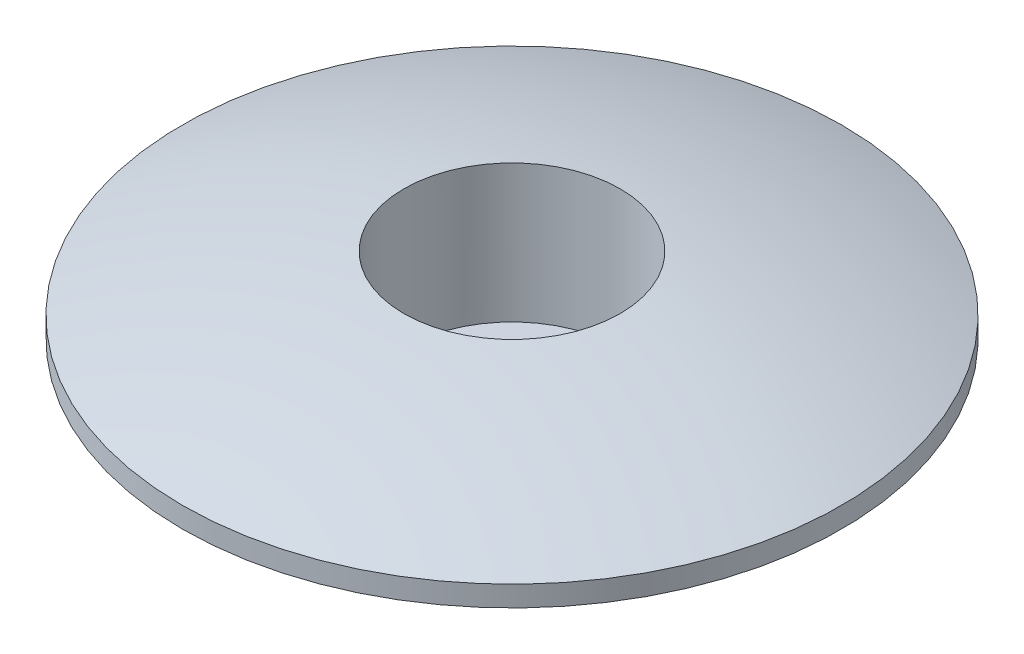
from build123d import *

# Parameters (mm, degrees)
ESQUISSE2_R             = 3.25
ENL_V_MAT_EXTRU_1_DEPTH = 10.5
ENL_V_START             = -2.5
ESQUISSE3_R             = 5.25
ENL_V_MAT_EXTRU_2_DEPTH = 7.880262221


with BuildPart() as part:
    # Esquisse1 → Révolution1 (revolve)
    with BuildSketch(Plane.XY, mode=Mode.PRIVATE) as r_volution1_sk:
        with BuildLine():
            Line((-16, 6.5), (-16, 5.5))
            Line((-16, 5.5), (-14.25, 5.5))
            Line((-14.25, 5.5), (-14.25, 4.5))
            ThreePointArc((-14.25, 4.5), (-9.106739847, 3.315312536), (-5, 0))
            Line((-5, 0), (0, 0))
            Line((0, 0), (0, 9.5))
            ThreePointArc((0, 9.5), (-8.139410298, 8.74352159), (-16, 6.5))
        make_face()
    revolve(r_volution1_sk.sketch.rotate(Axis((0, 18.461307074, 0), (0, -1, 0)), 270), axis=Axis((0, 18.461307074, 0), (0, -1, 0)))  # turned: the seam where the file's is

    # Esquisse2 → Enlèv. mat.-Extru.1 (cut, through all)
    with BuildSketch(Plane.XZ):
        with Locations(Location((0, 0, 0), (0, 0, 270))):  # turned: the seam where the file's is
            Circle(ESQUISSE2_R)
    extrude(amount=-ENL_V_MAT_EXTRU_1_DEPTH, mode=Mode.SUBTRACT)

    # Esquisse3 → Enlèv. mat.-Extru.2 (cut, through all)
    with BuildSketch(Plane.XZ.offset(ENL_V_START)):
        with Locations(Location((0, 0, 0), (0, 0, 270))):  # turned: the seam where the file's is
            Circle(ESQUISSE3_R)
    extrude(amount=-ENL_V_MAT_EXTRU_2_DEPTH, mode=Mode.SUBTRACT)


solid = part.part
